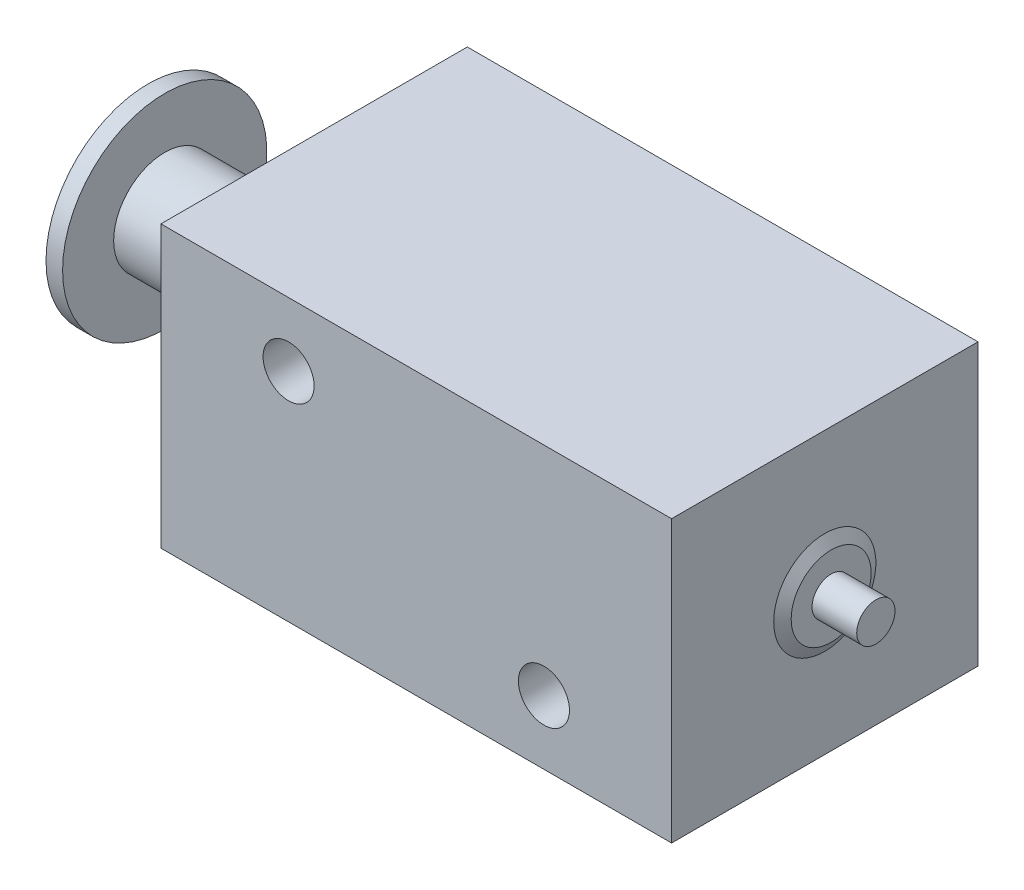
from build123d import *

# Parameters (mm, degrees)
SKETCH1_W           = 20
SKETCH1_H           = 12
BOSS_EXTRUDE1_DEPTH = 5.5
SKETCH2_R           = 1
CUT_EXTRUDE1_DEPTH  = 3


with BuildPart() as part:
    # Sketch1 → Boss-Extrude1 (new body, symmetric)
    with BuildSketch(Plane(origin=(0, 0, 0), x_dir=(1, 0, 0), z_dir=(0, 1, 0))):
        Rectangle(SKETCH1_W, SKETCH1_H)
    extrude(amount=BOSS_EXTRUDE1_DEPTH, both=True)

    # Sketch2 → Cut-Extrude1 (cut)
    with BuildSketch(Plane.XY.offset(6)):
        with Locations((5, -3)):
            Circle(SKETCH2_R)
        with Locations((-5, 3)):
            Circle(SKETCH2_R)
    extrude(amount=-CUT_EXTRUDE1_DEPTH, mode=Mode.SUBTRACT)

    # Sketch3 → Revolve1 (revolve)
    with BuildSketch(Plane(origin=(0, 0, 0), x_dir=(1, 0, 0), z_dir=(0, 1, 0))):
        Polygon((12, 0), (12, 0.75), (10.25, 0.75), (10.25, 1.566987298), (10, 2), (-15.85, 2), (-15.85, 4), (-16.5, 4), (-16.5, 2), (-17.5, 2), (-17.5, 0), align=None)
    revolve(axis=Axis((-17.5, 0, 0), (1, 0, 0)))


solid = part.part
